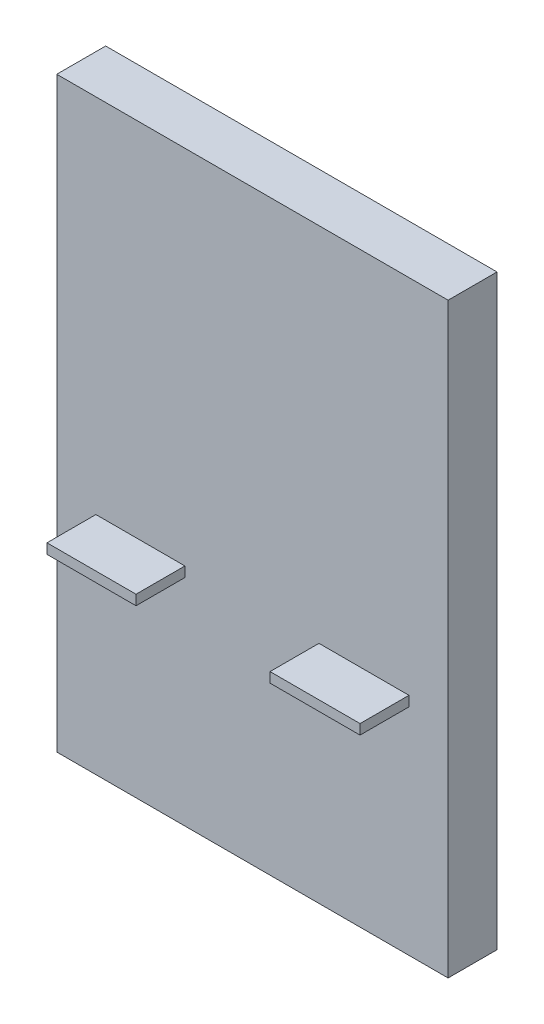
from build123d import *

# Parameters (mm, degrees)
SKETCH1_W           = 2
SKETCH1_H           = 3
BOSS_EXTRUDE1_DEPTH = 0.25
SKETCH2_W           = 0.455012626
SKETCH2_H           = 0.051193531
SKETCH2_W_2         = 0.46
BOSS_EXTRUDE2_DEPTH = 0.25


with BuildPart() as part:
    # Sketch1 → Boss-Extrude1 (new body)
    with BuildSketch(Plane.XY):
        with Locations((0, 1.5)):
            Rectangle(SKETCH1_W, SKETCH1_H)
    extrude(amount=-BOSS_EXTRUDE1_DEPTH)

    # Sketch2 → Boss-Extrude2 (add)
    with BuildSketch(Plane.XY):
        with Locations((-0.572493687, 1.125596766)):
            Rectangle(SKETCH2_W, SKETCH2_H)
        with Locations((0.57, 1.125596766)):
            Rectangle(SKETCH2_W_2, SKETCH2_H)
    extrude(amount=BOSS_EXTRUDE2_DEPTH)


solid = part.part
